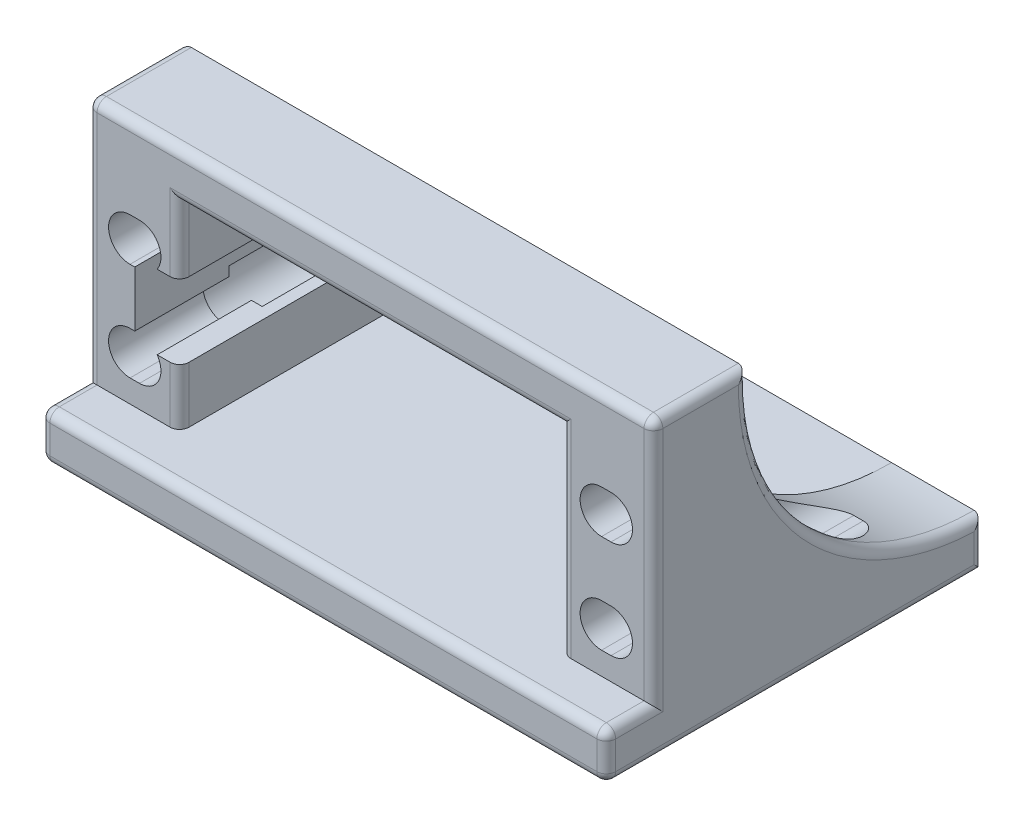
from build123d import *

# Parameters (mm, degrees)
SKETCH1_W            = 60
SKETCH1_H            = 40
BOSS_EXTRUDE1_DEPTH  = 5
SKETCH2_W            = 9.75
SKETCH2_H            = 10
BOSS_EXTRUDE2_DEPTH  = 26
BOSS_EXTRUDE3_DEPTH  = 9.75
CUT_EXTRUDE1_DEPTH   = 36
SKETCH5_W            = 10
SKETCH5_H            = 5
BOSS_EXTRUDE4_DEPTH  = 40.5
WIRE_CUT_OUT_DEPTH   = 36.0000001
WASHER_CUT_OUT_DEPTH = 25
FILLET1_R            = 1


with BuildPart() as part:
    # Sketch1 → Boss-Extrude1 (new body)
    with BuildSketch(Plane(origin=(0, 0, 0), x_dir=(1, 0, 0), z_dir=(0, 1, 0))):
        with Locations((30, 20)):
            Rectangle(SKETCH1_W, SKETCH1_H)
    extrude(amount=BOSS_EXTRUDE1_DEPTH)

    # Sketch2 → Boss-Extrude2 (add)
    with BuildSketch(Plane(origin=(0, 5, 0), x_dir=(1, 0, 0), z_dir=(0, 1, 0))):
        with Locations((4.875, 10)):
            Rectangle(SKETCH2_W, SKETCH2_H)
        with Locations((55.125, 10)):
            Rectangle(SKETCH2_W, SKETCH2_H)
    extrude(amount=BOSS_EXTRUDE2_DEPTH)

    # Sketch3 → Boss-Extrude3 (add)
    with BuildSketch(Plane.ZY):
        with BuildLine():
            Line((-15, 30), (-15, 5))
            Line((-15, 5), (-40, 5))
            ThreePointArc((-40, 5), (-22.32233047, 12.32233047), (-15, 30))
        make_face()
    boss_extrude3 = extrude(amount=-BOSS_EXTRUDE3_DEPTH)

    # Mirror2: Boss-Extrude3 across plane
    add(boss_extrude3.mirror(Plane(origin=(30, 0, 0), x_dir=(0, 0, 1), z_dir=(1, 0, 0))))

    # Sketch4 → Cut-Extrude1 (cut, through all)
    with BuildSketch(Plane.XY.offset(-5)):
        with BuildLine():
            Line((4.5, 22.388), (5.5, 22.388))
            ThreePointArc((5.5, 22.388), (7.775, 20.113), (5.5, 17.838))
            Line((5.5, 17.838), (4.5, 17.838))
            ThreePointArc((4.5, 17.838), (2.225, 20.113), (4.5, 22.388))
        make_face()
        with BuildLine():
            Line((4.5, 11.952), (5.5, 11.952))
            ThreePointArc((5.5, 11.952), (7.775, 9.677), (5.5, 7.402))
            Line((5.5, 7.402), (4.5, 7.402))
            ThreePointArc((4.5, 7.402), (2.225, 9.677), (4.5, 11.952))
        make_face()
        with BuildLine():
            Line((55.5, 11.952), (54.5, 11.952))
            ThreePointArc((54.5, 11.952), (52.225, 9.677), (54.5, 7.402))
            Line((54.5, 7.402), (55.5, 7.402))
            ThreePointArc((55.5, 7.402), (57.775, 9.677), (55.5, 11.952))
        make_face()
        with BuildLine():
            Line((55.5, 22.388), (54.5, 22.388))
            ThreePointArc((54.5, 22.388), (52.225, 20.113), (54.5, 17.838))
            Line((54.5, 17.838), (55.5, 17.838))
            ThreePointArc((55.5, 17.838), (57.775, 20.113), (55.5, 22.388))
        make_face()
    extrude(amount=-CUT_EXTRUDE1_DEPTH, mode=Mode.SUBTRACT)

    # Sketch5 → Boss-Extrude4 (add)
    with BuildSketch(Plane(origin=(9.75, 0, 0), x_dir=(0, 0, -1), z_dir=(1, 0, 0))):
        with Locations((10, 28.5)):
            Rectangle(SKETCH5_W, SKETCH5_H)
    extrude(amount=BOSS_EXTRUDE4_DEPTH)

    # Sketch6 → Wire_Cut_Out (cut, through all)
    with BuildSketch(Plane.XY.offset(-5)):
        with BuildLine():
            Line((5.5, 17.838), (5, 17.838))
            Line((5, 17.838), (5, 11.952))
            Line((5, 11.952), (5.5, 11.952))
            ThreePointArc((5.5, 11.952), (6.559361256, 11.690300457), (7.375, 10.965409873))
            Line((7.375, 10.965409873), (9.75, 10.965409873))
            Line((9.75, 10.965409873), (9.75, 18.824590127))
            Line((9.75, 18.824590127), (7.375, 18.824590127))
            ThreePointArc((7.375, 18.824590127), (6.559361256, 18.099699543), (5.5, 17.838))
        make_face()
        with BuildLine():
            Line((5, 18.824590127), (5, 17.838))
            Line((5, 17.838), (5.5, 17.838))
            ThreePointArc((5.5, 17.838), (6.559361256, 18.099699543), (7.375, 18.824590127))
            Line((7.375, 18.824590127), (5, 18.824590127))
        make_face()
        with BuildLine():
            Line((5.5, 11.952), (5, 11.952))
            Line((5, 11.952), (5, 10.965409873))
            Line((5, 10.965409873), (7.375, 10.965409873))
            ThreePointArc((7.375, 10.965409873), (6.559361256, 11.690300457), (5.5, 11.952))
        make_face()
    extrude(amount=-WIRE_CUT_OUT_DEPTH, mode=Mode.SUBTRACT)

    # Sketch8 → Washer_Cut_Out (cut)
    with BuildSketch(Plane(origin=(0, 0, -40), x_dir=(-1, 0, 0), z_dir=(0, 0, -1))):
        with BuildLine():
            Line((-55.5, 23.388), (-54.5, 23.388))
            ThreePointArc((-54.5, 23.388), (-51.225, 20.113), (-54.5, 16.838))
            Line((-54.5, 16.838), (-55.5, 16.838))
            ThreePointArc((-55.5, 16.838), (-58.775, 20.113), (-55.5, 23.388))
        make_face()
        with BuildLine():
            Line((-55.5, 12.952), (-54.5, 12.952))
            ThreePointArc((-54.5, 12.952), (-51.225, 9.677), (-54.5, 6.402))
            Line((-54.5, 6.402), (-55.5, 6.402))
            ThreePointArc((-55.5, 6.402), (-58.775, 9.677), (-55.5, 12.952))
        make_face()
        with BuildLine():
            Line((-5.5, 23.388), (-4.5, 23.388))
            ThreePointArc((-4.5, 23.388), (-1.225, 20.113), (-4.5, 16.838))
            Line((-4.5, 16.838), (-5.5, 16.838))
            ThreePointArc((-5.5, 16.838), (-8.775, 20.113), (-5.5, 23.388))
        make_face()
        with BuildLine():
            Line((-5.5, 12.952), (-4.5, 12.952))
            ThreePointArc((-4.5, 12.952), (-1.225, 9.677), (-4.5, 6.402))
            Line((-4.5, 6.402), (-5.5, 6.402))
            ThreePointArc((-5.5, 6.402), (-8.775, 9.677), (-5.5, 12.952))
        make_face()
    extrude(amount=-WASHER_CUT_OUT_DEPTH, mode=Mode.SUBTRACT)

    # Fillet1
    fillet1_edges = [part.edges().sort_by_distance(p)[0] for p in [
        (60, 5, -2.5),
        (0, 5, -2.5),
        (50.25, 15.5, -5),
        (9.75, 22.412295064, -5),
        (30, 26, -15),
        (30, 26, -5),
        (0, 30.5, -15),
        (0, 18, -5),
        (9.75, 6.538704712, -31.364745319),
        (9.75, 7.982704936, -5),
        (0, 31, -10),
        (30, 31, -5),
        (60, 18, -5),
        (60, 30.5, -15),
        (60, 31, -10),
        (0, 12.32233047, -22.32233047),
        (60, 12.32233047, -22.32233047),
        (60, 0, -20),
        (30, 0, 0),
        (0, 0, -20),
        (0, 2.5, -40),
        (60, 2.5, -40),
        (60, 2.5, 0),
        (0, 2.5, 0),
        (30, 5, 0),
    ]]
    fillet(fillet1_edges, radius=FILLET1_R)


solid = part.part
